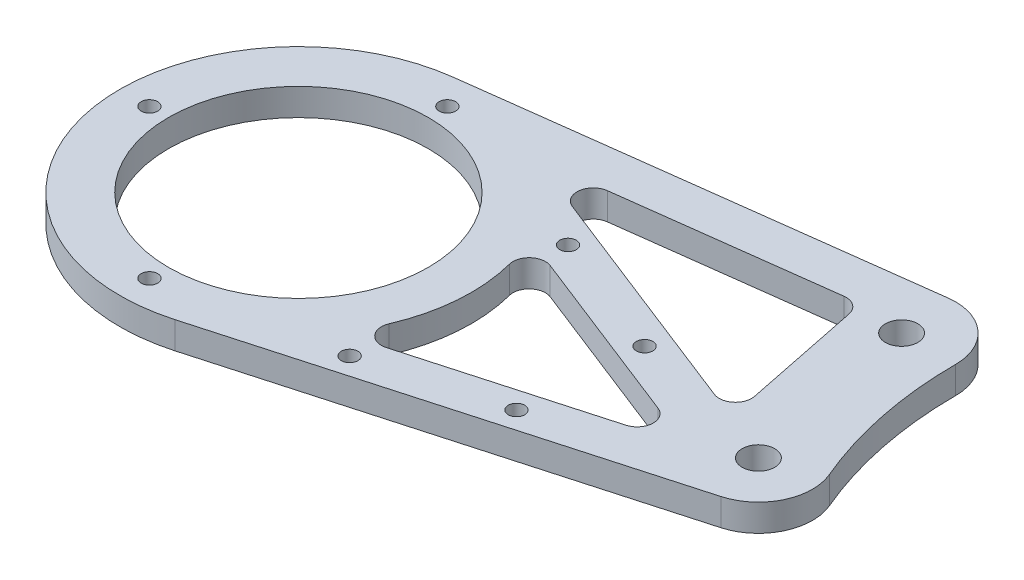
from build123d import *

# Parameters (mm, degrees)
SKETCH_1_R          = 2.025
SKETCH_1_R_2        = 13.1
SKETCH_1_R_3        = 3
EXTRUDE_1_DEPTH     = 5
SKETCH_3_R          = 24
CUT_EXTRUDE_2_DEPTH = 10
CUT_EXTRUDE_3_DEPTH = 10
FILLET_1_R          = 3
SKETCH_7_R          = 1.525
CUT_EXTRUDE_4_DEPTH = 10


with BuildPart() as part:
    # 草图1 → 凸台-拉伸1 (new body)
    with BuildSketch(Plane(origin=(0, 0, 0), x_dir=(1, 0, 0), z_dir=(0, 1, 0))):
        with BuildLine():
            Line((76.972140647, 43.13107423), (-4.193547259, 32.732463418))
            ThreePointArc((-4.193547259, 32.732463418), (-32.337515252, -6.579141836), (8.929411765, -31.768940894))
            Line((8.929411765, -31.768940894), (87.705882353, -9.626951786))
            ThreePointArc((87.705882353, -9.626951786), (94.014523475, -4.328783491), (94.205048973, 3.907310252))
            ThreePointArc((94.205048973, 3.907310252), (89.748559809, 18.25955029), (88.242912543, 33.212145922))
            ThreePointArc((88.242912543, 33.212145922), (84.849435117, 40.719066694), (76.972140647, 43.13107423))
        make_face()
        with Locations((0, 17.5)):
            Circle(SKETCH_1_R, mode=Mode.SUBTRACT)
        with Locations((8.75, 15.155444566)):
            Circle(SKETCH_1_R, mode=Mode.SUBTRACT)
        with Locations((-8.75, -15.155444566)):
            Circle(SKETCH_1_R, mode=Mode.SUBTRACT)
        with Locations((0, -17.5)):
            Circle(SKETCH_1_R, mode=Mode.SUBTRACT)
        with Locations((-15.155444566, -8.75)):
            Circle(SKETCH_1_R, mode=Mode.SUBTRACT)
        with Locations((8.75, -15.155444566)):
            Circle(SKETCH_1_R, mode=Mode.SUBTRACT)
        with Locations((15.155444566, -8.75)):
            Circle(SKETCH_1_R, mode=Mode.SUBTRACT)
        with Locations((-17.5, 0)):
            Circle(SKETCH_1_R, mode=Mode.SUBTRACT)
        Circle(SKETCH_1_R_2, mode=Mode.SUBTRACT)
        with Locations((-15.155444566, 8.75)):
            Circle(SKETCH_1_R, mode=Mode.SUBTRACT)
        with Locations((17.5, 0)):
            Circle(SKETCH_1_R, mode=Mode.SUBTRACT)
        with Locations((15.155444566, 8.75)):
            Circle(SKETCH_1_R, mode=Mode.SUBTRACT)
        with Locations((-8.75, 15.155444566)):
            Circle(SKETCH_1_R, mode=Mode.SUBTRACT)
        with Locations((85, 0)):
            Circle(SKETCH_1_R_3, mode=Mode.SUBTRACT)
        with Locations((78.242912543, 33.212145922)):
            Circle(SKETCH_1_R_3, mode=Mode.SUBTRACT)
    extrude(amount=EXTRUDE_1_DEPTH)

    # 草图3 → 切除-拉伸2 (cut)
    with BuildSketch(Plane(origin=(0, 5, 0), x_dir=(1, 0, 0), z_dir=(0, 1, 0))):
        Circle(SKETCH_3_R)
    extrude(amount=-CUT_EXTRUDE_2_DEPTH, mode=Mode.SUBTRACT)

    # 草图4 → 切除-拉伸3 (cut)
    with BuildSketch(Plane(origin=(0, 5, 0), x_dir=(1, 0, 0), z_dir=(0, 1, 0))):
        Polygon((69.770383541, 34.143027562), (75.881597407, 4.105451761), (16.636114037, 27.335685646), align=None)
        with BuildLine():
            ThreePointArc((32, 0), (30.461655113, -9.802426627), (25.994527014, -18.662383699))
            Line((25.994527014, -18.662383699), (76.108728609, -4.576602785))
            Line((76.108728609, -4.576602785), (28.785186198, 13.979021981))
            ThreePointArc((28.785186198, 13.979021981), (31.185942012, 7.171960739), (32, 0))
        make_face()
    extrude(amount=-CUT_EXTRUDE_3_DEPTH, mode=Mode.SUBTRACT)

    # 圆角1
    fillet_1_edges = [part.edges().sort_by_distance(p)[0] for p in [
        (25.994527014, 2.5, 18.662383699),
        (28.785186198, 2.5, -13.979021981),
        (76.108728609, 2.5, 4.576602785),
        (69.770383541, 2.5, -34.143027562),
        (75.881597407, 2.5, -4.105451761),
        (16.636114037, 2.5, -27.335685646),
    ]]
    fillet(fillet_1_edges, radius=FILLET_1_R)

    # 草图7 → 切除-拉伸4 (cut)
    with BuildSketch(Plane.XZ):
        with Locations((0, -27.522163408)):
            Circle(SKETCH_7_R)
        with Locations((33.321534862, -16.496811603)):
            Circle(SKETCH_7_R)
        with Locations((-27.522163408, 0)):
            Circle(SKETCH_7_R)
        with Locations((0, 27.522163408)):
            Circle(SKETCH_7_R)
        with Locations((30.901702525, 21.438107622)):
            Circle(SKETCH_7_R)
        with Locations((56.596303964, -7.370743267)):
            Circle(SKETCH_7_R)
        with Locations((54.969081991, 14.673401739)):
            Circle(SKETCH_7_R)
    extrude(amount=-CUT_EXTRUDE_4_DEPTH, mode=Mode.SUBTRACT)


solid = part.part
